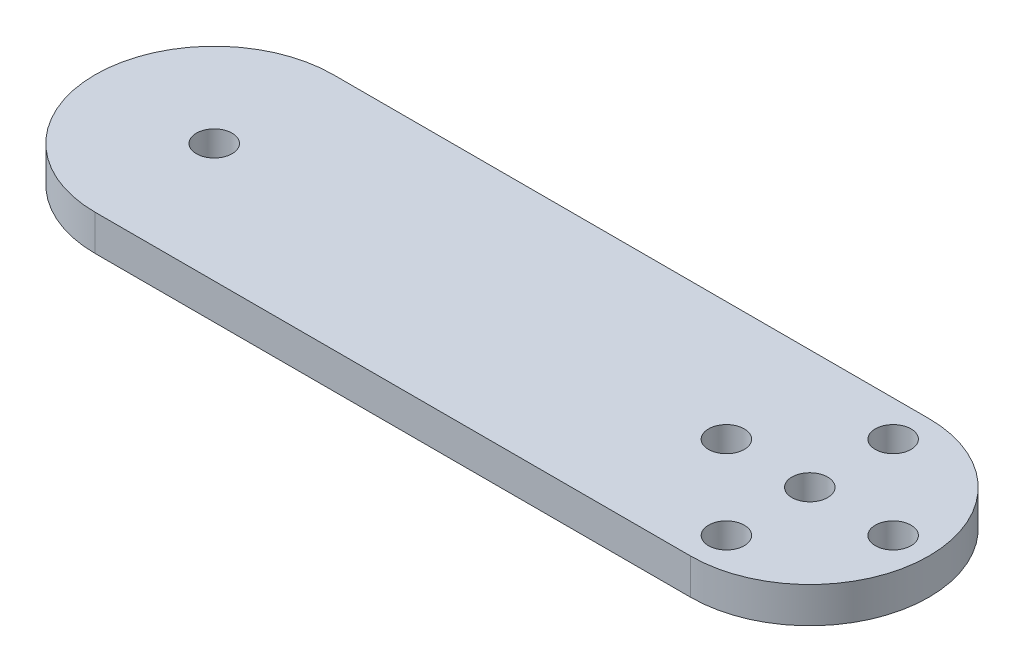
from build123d import *

# Parameters (mm, degrees)
SKETCH1_R           = 1.5
BOSS_EXTRUDE1_DEPTH = 3


with BuildPart() as part:
    # Sketch1 → Boss-Extrude1 (new body)
    with BuildSketch(Plane(origin=(0, 0, 0), x_dir=(1, 0, 0), z_dir=(0, 1, 0))):
        with BuildLine():
            Line((0, 0), (-50, 0))
            ThreePointArc((-50, 0), (-60, 10), (-50, 20))
            Line((-50, 20), (0, 20))
            ThreePointArc((0, 20), (10, 10), (0, 0))
        make_face()
        with Locations((0, 10)):
            Circle(SKETCH1_R, mode=Mode.SUBTRACT)
        with Locations((0, 17)):
            Circle(SKETCH1_R, mode=Mode.SUBTRACT)
        with Locations((0, 3)):
            Circle(SKETCH1_R, mode=Mode.SUBTRACT)
        with Locations((7, 10)):
            Circle(SKETCH1_R, mode=Mode.SUBTRACT)
        with Locations((-7, 10)):
            Circle(SKETCH1_R, mode=Mode.SUBTRACT)
        with Locations((-50, 10)):
            Circle(SKETCH1_R, mode=Mode.SUBTRACT)
    extrude(amount=BOSS_EXTRUDE1_DEPTH)


solid = part.part
